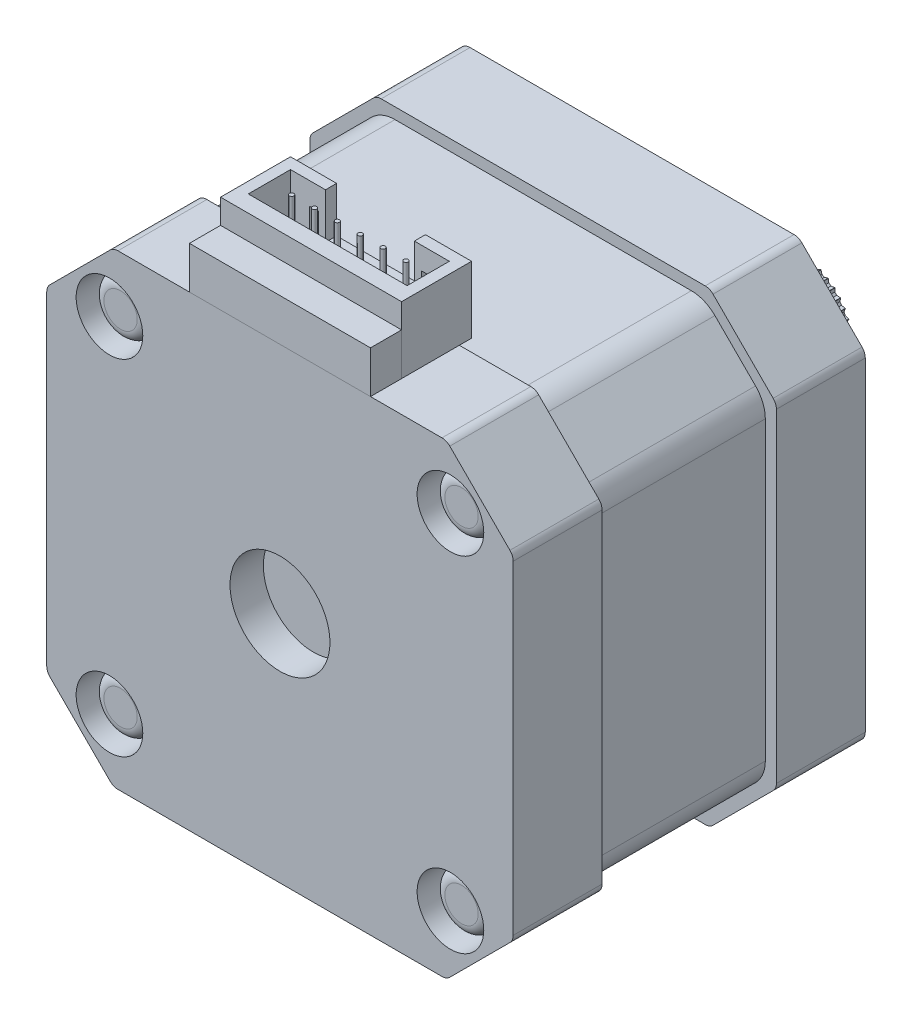
from build123d import *

# Parameters (mm, degrees)
SKETCH1_W              = 42
SKETCH1_H              = 42
BOSS_EXTRUDE1_DEPTH    = 8
CHAMFER1_SIZE          = 6
FILLET1_R              = 1
BOSS_EXTRUDE4_DEPTH    = 15.7
FILLET2_R              = 3
BOSS_EXTRUDE5_DEPTH    = 8
SKETCH7_R              = 1.5
CUT_EXTRUDE1_DEPTH     = 44.438347114
SKETCH8_R              = 4.5
CUT_EXTRUDE2_DEPTH     = 44.438347114
SKETCH9_R              = 11
SKETCH9_R_2            = 4.5
BOSS_EXTRUDE7_DEPTH    = 1.8
FILLET4_R              = 0.5
FILLET5_R              = 0.2
SKETCH12_R             = 4.5
BOSS_EXTRUDE8_DEPTH    = 10
BOSS_EXTRUDE9_DEPTH    = 34
SKETCH17_R             = 4.5
SKETCH17_R_2           = 4.25
BOSS_EXTRUDE10_DEPTH   = 9
CUT_EXTRUDE3_DEPTH     = 9
CIRPATTERN1_COUNT      = 38
SKETCH24_W             = 16.3
SKETCH24_H             = 3.8
BOSS_EXTRUDE17_DEPTH   = 2.8
SKETCH25_W             = 16.3
SKETCH25_H             = 6
BOSS_EXTRUDE18_DEPTH   = 6.3
SKETCH26_W             = 8
SKETCH26_H             = 4.1
CUT_EXTRUDE6_DEPTH     = 4
SKETCH28_W             = 14.3
SKETCH28_H             = 3.8
CUT_EXTRUDE7_DEPTH     = 5
CUT_EXTRUDE8_DEPTH     = 1
SKETCH29_R             = 0.2
BOSS_EXTRUDE19_DEPTH   = 5
SKETCH30_R             = 3
SKETCH30_R_2           = 1.5
CUT_EXTRUDE9_DEPTH     = 4
SKETCH31_R             = 2.5
BOSS_EXTRUDE20_DEPTH   = 3
BOSS_EXTRUDE20_2_DEPTH = 3
BOSS_EXTRUDE20_3_DEPTH = 3
BOSS_EXTRUDE20_4_DEPTH = 3
FILLET6_R              = 1
FILLET7_R              = 1
FILLET8_R              = 1
FILLET9_R              = 1


with BuildPart() as part:
    # Sketch1 → Boss-Extrude1 (new body)
    with BuildSketch(Plane.XY):
        Rectangle(SKETCH1_W, SKETCH1_H)
    extrude(amount=BOSS_EXTRUDE1_DEPTH)

    # Chamfer1
    chamfer1_edges = [part.edges().sort_by_distance(p)[0] for p in [
        (21, -21, 4),
        (-21, -21, 4),
        (-21, 21, 4),
        (21, 21, 4),
    ]]
    chamfer(chamfer1_edges, length=CHAMFER1_SIZE)

    # Fillet1
    fillet1_edges = [part.edges().sort_by_distance(p)[0] for p in [
        (15, -21, 4),
        (-15, -21, 4),
        (-21, 15, 4),
        (-21, -15, 4),
        (21, 15, 4),
        (21, -15, 4),
        (-15, 21, 4),
        (15, 21, 4),
    ]]
    fillet(fillet1_edges, radius=FILLET1_R)


with BuildPart() as body_2:
    # Sketch3 → Boss-Extrude4 (new body)
    with BuildSketch(Plane(origin=(0, 0, 0), x_dir=(-1, 0, 0), z_dir=(0, 0, -1))):
        Polygon((-14.585786438, 20), (14.585786438, 20), (20, 14.585786438), (20, -14.585786438), (14.585786438, -20), (-14.585786438, -20), (-20, -14.585786438), (-20, 14.585786438), align=None)
    extrude(amount=BOSS_EXTRUDE4_DEPTH)

    # Fillet2
    fillet2_edges = [body_2.edges().sort_by_distance(p)[0] for p in [
        (14.585786438, 20, -7.85),
        (-14.585786438, 20, -7.85),
        (-20, 14.585786438, -7.85),
        (-20, -14.585786438, -7.85),
        (-14.585786438, -20, -7.85),
        (14.585786438, -20, -7.85),
        (20, -14.585786438, -7.85),
        (20, 14.585786438, -7.85),
    ]]
    fillet(fillet2_edges, radius=FILLET2_R)


with BuildPart() as body_3:
    # Sketch6 → Boss-Extrude5 (new body)
    with BuildSketch(Plane(origin=(0, 0, -15.7), x_dir=(-1, 0, 0), z_dir=(0, 0, -1))):
        with BuildLine():
            Line((15.292893219, -20.707106781), (20.707106781, -15.292893219))
            ThreePointArc((20.707106781, -15.292893219), (20.923879533, -14.96846987), (21, -14.585786438))
            Line((21, -14.585786438), (21, 14.585786438))
            ThreePointArc((21, 14.585786438), (20.923879533, 14.96846987), (20.707106781, 15.292893219))
            Line((20.707106781, 15.292893219), (15.292893219, 20.707106781))
            ThreePointArc((15.292893219, 20.707106781), (14.96846987, 20.923879533), (14.585786438, 21))
            Line((14.585786438, 21), (-14.585786438, 21))
            ThreePointArc((-14.585786438, 21), (-14.96846987, 20.923879533), (-15.292893219, 20.707106781))
            Line((-15.292893219, 20.707106781), (-20.707106781, 15.292893219))
            ThreePointArc((-20.707106781, 15.292893219), (-20.923879533, 14.96846987), (-21, 14.585786438))
            Line((-21, 14.585786438), (-21, -14.585786438))
            ThreePointArc((-21, -14.585786438), (-20.923879533, -14.96846987), (-20.707106781, -15.292893219))
            Line((-20.707106781, -15.292893219), (-15.292893219, -20.707106781))
            ThreePointArc((-15.292893219, -20.707106781), (-14.96846987, -20.923879533), (-14.585786438, -21))
            Line((-14.585786438, -21), (14.585786438, -21))
            ThreePointArc((14.585786438, -21), (14.96846987, -20.923879533), (15.292893219, -20.707106781))
        make_face()
    extrude(amount=BOSS_EXTRUDE5_DEPTH)


with BuildPart() as cut_extrude1_tool:
    # Sketch7 → Cut-Extrude1 (new, through all)
    with BuildSketch(Plane.XY.offset(8)):
        with Locations(Location((-15.35, 15.5, 0), (0, 0, 180))):
            Circle(SKETCH7_R)
        with Locations(Location((15.35, 15.5, 0), (0, 0, 180))):
            Circle(SKETCH7_R)
        with Locations(Location((15.35, -15.5, 0), (0, 0, 180))):
            Circle(SKETCH7_R)
        with Locations(Location((-15.35, -15.5, 0), (0, 0, 180))):
            Circle(SKETCH7_R)
    extrude(amount=-CUT_EXTRUDE1_DEPTH)


with BuildPart() as part_1:
    add(part.part)

    # Cut-Extrude1: cut by cut_extrude1_tool
    add(cut_extrude1_tool.part, mode=Mode.SUBTRACT)


with BuildPart() as body_2_1:
    add(body_2.part)

    # Cut-Extrude1: cut by cut_extrude1_tool
    add(cut_extrude1_tool.part, mode=Mode.SUBTRACT)


with BuildPart() as body_3_1:
    add(body_3.part)

    # Cut-Extrude1: cut by cut_extrude1_tool
    add(cut_extrude1_tool.part, mode=Mode.SUBTRACT)


with BuildPart() as cut_extrude2_tool:
    # Sketch8 → Cut-Extrude2 (new, through all)
    with BuildSketch(Plane(origin=(0, 0, -23.7), x_dir=(-1, 0, 0), z_dir=(0, 0, -1))):
        Circle(SKETCH8_R)
    extrude(amount=-CUT_EXTRUDE2_DEPTH)


with BuildPart() as part_2:
    add(part_1.part)

    # Cut-Extrude2: cut by cut_extrude2_tool
    add(cut_extrude2_tool.part, mode=Mode.SUBTRACT)

    # Sketch30 → Cut-Extrude9 (cut)
    with BuildSketch(Plane.XY.offset(8)):
        with Locations((-15.35, 15.5)):
            Circle(SKETCH30_R)
        with Locations((-15.35, 15.5)):
            Circle(SKETCH30_R_2, mode=Mode.SUBTRACT)
        with Locations((15.35, 15.5)):
            Circle(SKETCH30_R)
        with Locations((15.35, 15.5)):
            Circle(SKETCH30_R_2, mode=Mode.SUBTRACT)
        with Locations((15.35, -15.5)):
            Circle(SKETCH30_R)
        with Locations((15.35, -15.5)):
            Circle(SKETCH30_R_2, mode=Mode.SUBTRACT)
        with Locations((-15.35, -15.5)):
            Circle(SKETCH30_R)
        with Locations((-15.35, -15.5)):
            Circle(SKETCH30_R_2, mode=Mode.SUBTRACT)
    extrude(amount=-CUT_EXTRUDE9_DEPTH, mode=Mode.SUBTRACT)


with BuildPart() as body_2_2:
    add(body_2_1.part)

    # Cut-Extrude2: cut by cut_extrude2_tool
    add(cut_extrude2_tool.part, mode=Mode.SUBTRACT)



with BuildPart() as body_3_2:
    add(body_3_1.part)

    # Cut-Extrude2: cut by cut_extrude2_tool
    add(cut_extrude2_tool.part, mode=Mode.SUBTRACT)

    # Sketch9 → Boss-Extrude7 (add)
    with BuildSketch(Plane(origin=(0, 0, -23.7), x_dir=(-1, 0, 0), z_dir=(0, 0, -1))):
        Circle(SKETCH9_R)
        Circle(SKETCH9_R_2, mode=Mode.SUBTRACT)
    extrude(amount=BOSS_EXTRUDE7_DEPTH)

    # Fillet4
    fillet4_edges = [body_3_2.edges().sort_by_distance(p)[0] for p in [
        (11, 0, -23.7),
    ]]
    fillet(fillet4_edges, radius=FILLET4_R)

    # Fillet5
    fillet5_edges = [body_3_2.edges().sort_by_distance(p)[0] for p in [
        (11, 0, -25.5),
    ]]
    fillet(fillet5_edges, radius=FILLET5_R)


with BuildPart() as body_4:
    # Sketch12 → Boss-Extrude8 (new body)
    with BuildSketch(Plane.XY.offset(5)):
        with Locations(Location((0, 0, 0), (0, 0, 180))):
            Circle(SKETCH12_R)
    extrude(amount=-BOSS_EXTRUDE8_DEPTH)


with BuildPart() as body_2_3:
    add(body_2_2.part)

    add(body_3_2.part)  # Boss-Extrude9 merges body 3

    add(body_4.part)  # Boss-Extrude9 merges body 4
    # Sketch16 → Boss-Extrude9 (add)
    with BuildSketch(Plane(origin=(0, 0, -5), x_dir=(-1, 0, 0), z_dir=(0, 0, -1))):
        with BuildLine():
            Line((0, 2.25), (2.25, 0))
            ThreePointArc((2.25, 0), (-1.590990258, -1.590990258), (0, 2.25))
        make_face()
    extrude(amount=BOSS_EXTRUDE9_DEPTH)


with BuildPart() as body_3_2_1:
    # Sketch17 → Boss-Extrude10 (new body)
    with BuildSketch(Plane(origin=(0, 0, -39), x_dir=(-1, 0, 0), z_dir=(0, 0, -1))):
        Circle(SKETCH17_R)
        Circle(SKETCH17_R_2, mode=Mode.SUBTRACT)
        Circle(SKETCH17_R_2)
        with BuildLine():
            ThreePointArc((0, 2.25), (-1.590990258, -1.590990258), (2.25, 0))
            Line((2.25, 0), (0, 2.25))
        make_face(mode=Mode.SUBTRACT)
    extrude(amount=-BOSS_EXTRUDE10_DEPTH)

    # Sketch18 → Cut-Extrude3 (cut)
    with BuildSketch(Plane(origin=(0, 0, -39), x_dir=(-1, 0, 0), z_dir=(0, 0, -1))):
        with BuildLine():
            Line((-0.243411915, 4.493411915), (0, 4.25))
            ThreePointArc((0, 4.25), (0.12240573, 4.248236909), (0.244709901, 4.2429491))
            Line((0.244709901, 4.2429491), (0.476465347, 4.474704546))
            ThreePointArc((0.476465347, 4.474704546), (0.116901527, 4.498481303), (-0.243411915, 4.493411915))
        make_face()
    cut_extrude3 = extrude(amount=-CUT_EXTRUDE3_DEPTH, mode=Mode.SUBTRACT)

    # CirPattern1: Cut-Extrude3 ×38 about axis
    cirpattern1_axis = Axis((0, 0, 0), (0, 0, 1))
    for i in range(1, CIRPATTERN1_COUNT):
        add(cut_extrude3.rotate(cirpattern1_axis, i * 360 / CIRPATTERN1_COUNT), mode=Mode.SUBTRACT)


with BuildPart() as body_4_2:
    # Sketch24 → Boss-Extrude17 (new body)
    with BuildSketch(Plane.XY.offset(8)):
        with Locations((0, 22.9)):
            Rectangle(SKETCH24_W, SKETCH24_H)
    extrude(amount=-BOSS_EXTRUDE17_DEPTH)


with BuildPart() as body_5:
    # Sketch25 → Boss-Extrude18 (new body)
    with BuildSketch(Plane(origin=(0, 0, 5.2), x_dir=(-1, 0, 0), z_dir=(0, 0, -1))):
        with Locations((0, 24)):
            Rectangle(SKETCH25_W, SKETCH25_H)
    extrude(amount=BOSS_EXTRUDE18_DEPTH)

    # Sketch26 → Cut-Extrude6 (cut)
    with BuildSketch(Plane(origin=(0, 0, -1.1), x_dir=(-1, 0, 0), z_dir=(0, 0, -1))):
        with Locations((0, 24.95)):
            Rectangle(SKETCH26_W, SKETCH26_H)
    extrude(amount=-CUT_EXTRUDE6_DEPTH, mode=Mode.SUBTRACT)

    # Sketch28 → Cut-Extrude7 (cut)
    with BuildSketch(Plane(origin=(0, 27, 0), x_dir=(1, 0, 0), z_dir=(0, 1, 0))):
        with Locations((0, -1.8)):
            Rectangle(SKETCH28_W, SKETCH28_H)
    extrude(amount=-CUT_EXTRUDE7_DEPTH, mode=Mode.SUBTRACT)

    # Sketch26_4 → Cut-Extrude8 (cut)
    with BuildSketch(Plane(origin=(0, 0, -1.1), x_dir=(-1, 0, 0), z_dir=(0, 0, -1))):
        Polygon((-5.45, 25), (-5.45, 21), (5.45, 21), (5.45, 25), (4.65, 25), (4.65, 21.5), (-4.65, 21.5), (-4.65, 25), align=None)
    extrude(amount=-CUT_EXTRUDE8_DEPTH, mode=Mode.SUBTRACT)

    # Sketch29 → Boss-Extrude19 (add)
    with BuildSketch(Plane(origin=(0, 22, 0), x_dir=(1, 0, 0), z_dir=(0, 1, 0))):
        with Locations(Location((-5.147005039, -1.8, 0), (0, 0, 270))):
            Circle(SKETCH29_R)
        with Locations(Location((-3.088203024, -1.8, 0), (0, 0, 270))):
            Circle(SKETCH29_R)
        with Locations(Location((-1.029401008, -1.8, 0), (0, 0, 270))):
            Circle(SKETCH29_R)
        with Locations(Location((1.029401008, -1.8, 0), (0, 0, 270))):
            Circle(SKETCH29_R)
        with Locations(Location((3.088203024, -1.8, 0), (0, 0, 270))):
            Circle(SKETCH29_R)
        with Locations(Location((5.147005039, -1.8, 0), (0, 0, 270))):
            Circle(SKETCH29_R)
    extrude(amount=BOSS_EXTRUDE19_DEPTH)


with BuildPart() as body_6:
    # Sketch31 → Boss-Extrude20 (new body)
    with BuildSketch(Plane.XY.offset(4)):
        with Locations((15.35, 15.5)):
            Circle(SKETCH31_R)
    extrude(amount=BOSS_EXTRUDE20_DEPTH)

    # Fillet7
    fillet7_edges = [body_6.edges().sort_by_distance(p)[0] for p in [
        (12.85, 15.5, 7),
    ]]
    fillet(fillet7_edges, radius=FILLET7_R)


with BuildPart() as body_7:
    # Sketch31 → Boss-Extrude20 2 (new body)
    with BuildSketch(Plane.XY.offset(4)):
        with Locations((-15.35, 15.5)):
            Circle(SKETCH31_R)
    extrude(amount=BOSS_EXTRUDE20_2_DEPTH)

    # Fillet6
    fillet6_edges = [body_7.edges().sort_by_distance(p)[0] for p in [
        (-17.85, 15.5, 7),
    ]]
    fillet(fillet6_edges, radius=FILLET6_R)


with BuildPart() as body_8:
    # Sketch31 → Boss-Extrude20 3 (new body)
    with BuildSketch(Plane.XY.offset(4)):
        with Locations((15.35, -15.5)):
            Circle(SKETCH31_R)
    extrude(amount=BOSS_EXTRUDE20_3_DEPTH)

    # Fillet8
    fillet8_edges = [body_8.edges().sort_by_distance(p)[0] for p in [
        (12.85, -15.5, 7),
    ]]
    fillet(fillet8_edges, radius=FILLET8_R)


with BuildPart() as body_9:
    # Sketch31 → Boss-Extrude20 4 (new body)
    with BuildSketch(Plane.XY.offset(4)):
        with Locations((-15.35, -15.5)):
            Circle(SKETCH31_R)
    extrude(amount=BOSS_EXTRUDE20_4_DEPTH)

    # Fillet9
    fillet9_edges = [body_9.edges().sort_by_distance(p)[0] for p in [
        (-17.85, -15.5, 7),
    ]]
    fillet(fillet9_edges, radius=FILLET9_R)


solid = Compound([part_2.part, body_2_3.part, body_3_2_1.part, body_4_2.part, body_5.part, body_6.part, body_7.part, body_8.part, body_9.part])
